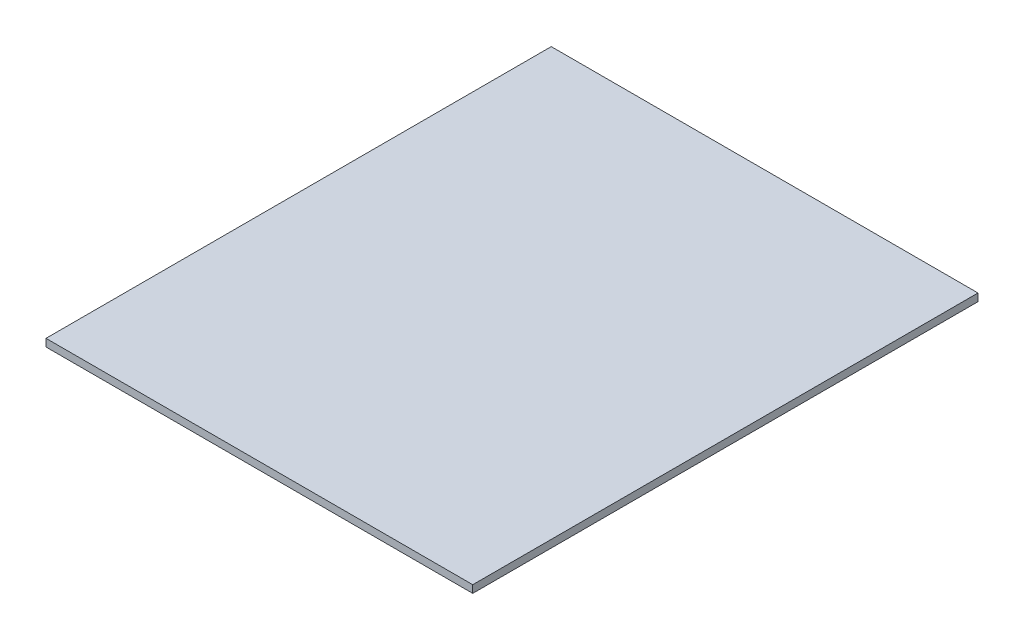
from build123d import *

# Parameters (mm, degrees)
SKETCH2_W      = 565.88
SKETCH2_H      = 670
EXTRUDE1_DEPTH = 10


with BuildPart() as part:
    # Sketch2 → Extrude1 (new body)
    with BuildSketch(Plane(origin=(0, 0, 0), x_dir=(1, 0, 0), z_dir=(0, 1, 0))):
        with Locations((282.94, 335)):
            Rectangle(SKETCH2_W, SKETCH2_H)
    extrude(amount=EXTRUDE1_DEPTH)


solid = part.part
